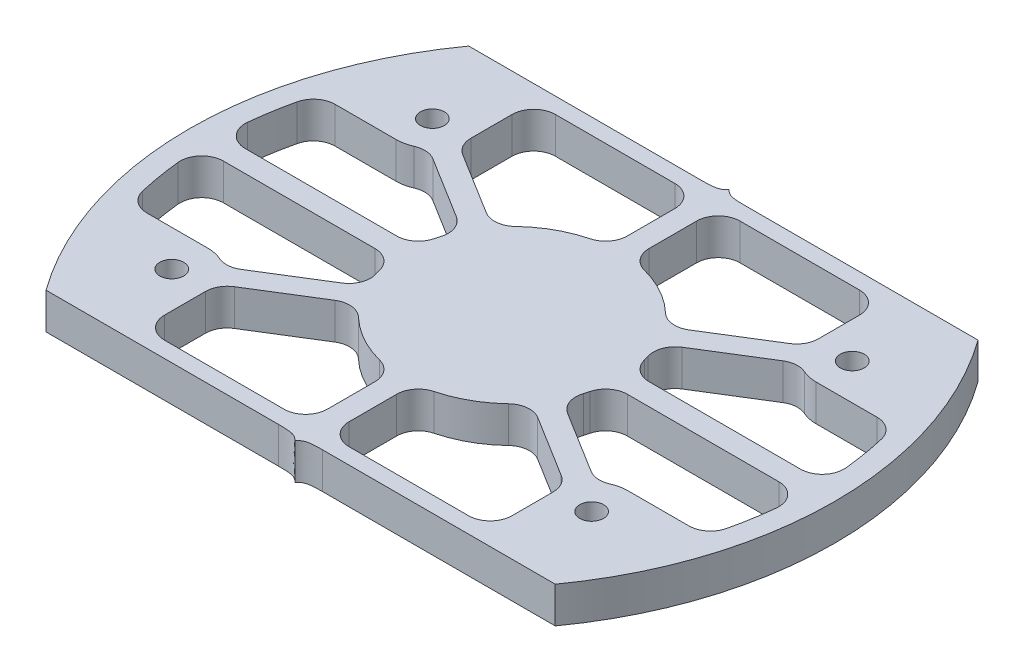
from build123d import *

# Parameters (mm, degrees)
EXTRUDE_1_DEPTH     = 5
CUT_EXTRUDE_1_DEPTH = 6
SKETCH_3_R          = 5
EXTRUDE_2_DEPTH     = 5
EXTRUDE_2_2_DEPTH   = 5
EXTRUDE_2_3_DEPTH   = 5
EXTRUDE_2_4_DEPTH   = 5
SKETCH_3_R_2        = 15
EXTRUDE_2_5_DEPTH   = 5
EXTRUDE_3_DEPTH     = 5
EXTRUDE_4_DEPTH     = 5
FILLET_1_R          = 3
M4X0_71_D           = 3.3
CUT_EXTRUDE_2_DEPTH = 6.0000001


with BuildPart() as part:
    # Эскиз1 → Бобышка-Вытянуть1 (new body)
    with BuildSketch(Plane(origin=(0, 0, 0), x_dir=(1, 0, 0), z_dir=(0, 1, 0))):
        with BuildLine():
            Line((79.165543512, 0), (10, 0))
            ThreePointArc((10, 0), (0, 30), (10, 60))
            Line((10, 60), (79.165543512, 60))
            ThreePointArc((79.165543512, 60), (89.165543512, 30), (79.165543512, 0))
        make_face()
    extrude(amount=EXTRUDE_1_DEPTH)

    # Эскиз2 → Вырез-Вытянуть1 (cut, through all)
    with BuildSketch(Plane(origin=(0, 5, 0), x_dir=(1, 0, 0), z_dir=(0, 1, 0))):
        with BuildLine():
            Line((11.529231877, 3), (77.636311635, 3))
            ThreePointArc((77.636311635, 3), (86.165543512, 30), (77.636311635, 57))
            Line((77.636311635, 57), (11.529231877, 57))
            ThreePointArc((11.529231877, 57), (3, 30), (11.529231877, 3))
        make_face()
    extrude(amount=-CUT_EXTRUDE_1_DEPTH, mode=Mode.SUBTRACT)



with BuildPart() as body_2:
    # Эскиз3 → Бобышка-Вытянуть2 (new body, through all)
    with BuildSketch(Plane(origin=(0, 5, 0), x_dir=(1, 0, 0), z_dir=(0, 1, 0))):
        with Locations((15.582771756, 48)):
            Circle(SKETCH_3_R)
    extrude(amount=-EXTRUDE_2_DEPTH)


with BuildPart() as body_3:
    # Эскиз3 → Extrude 2 2 (new body, through all)
    with BuildSketch(Plane(origin=(0, 5, 0), x_dir=(1, 0, 0), z_dir=(0, 1, 0))):
        with Locations((73.582771756, 48)):
            Circle(SKETCH_3_R)
    extrude(amount=-EXTRUDE_2_2_DEPTH)


with BuildPart() as body_4:
    # Эскиз3 → Extrude 2 3 (new body, through all)
    with BuildSketch(Plane(origin=(0, 5, 0), x_dir=(1, 0, 0), z_dir=(0, 1, 0))):
        with Locations((73.582771756, 12)):
            Circle(SKETCH_3_R)
    extrude(amount=-EXTRUDE_2_3_DEPTH)


with BuildPart() as body_5:
    # Эскиз3 → Extrude 2 4 (new body, through all)
    with BuildSketch(Plane(origin=(0, 5, 0), x_dir=(1, 0, 0), z_dir=(0, 1, 0))):
        with Locations((15.582771756, 12)):
            Circle(SKETCH_3_R)
    extrude(amount=-EXTRUDE_2_4_DEPTH)


with BuildPart() as body_6:
    # Эскиз3 → Extrude 2 5 (new body, through all)
    with BuildSketch(Plane(origin=(0, 5, 0), x_dir=(1, 0, 0), z_dir=(0, 1, 0))):
        with Locations((44.582771756, 30)):
            Circle(SKETCH_3_R_2)
    extrude(amount=-EXTRUDE_2_5_DEPTH)


with BuildPart() as part_1:
    add(part.part)

    add(body_2.part)  # Бобышка-Вытянуть3 merges body 2

    add(body_3.part)  # Бобышка-Вытянуть3 merges body 3

    add(body_4.part)  # Бобышка-Вытянуть3 merges body 4

    add(body_5.part)  # Бобышка-Вытянуть3 merges body 5

    add(body_6.part)  # Бобышка-Вытянуть3 merges body 6
    # Эскиз4 → Бобышка-Вытянуть3 (add, through all)
    with BuildSketch(Plane(origin=(0, 5, 0), x_dir=(1, 0, 0), z_dir=(0, 1, 0))):
        with BuildLine():
            ThreePointArc((31.111008092, 36.596331085), (31.838169263, 37.910442927), (32.693096677, 39.145251583))
            Line((32.693096677, 39.145251583), (20.426341357, 46.759099713))
            ThreePointArc((20.426341357, 46.759099713), (19.830972587, 45.363185691), (18.844252772, 44.210179215))
            Line((18.844252772, 44.210179215), (31.111008092, 36.596331085))
        make_face()
        with BuildLine():
            ThreePointArc((43.082771756, 44.924811557), (44.582771756, 45), (46.082771756, 44.924811557))
            Line((46.082771756, 44.924811557), (46.082771756, 57))
            Line((46.082771756, 57), (43.082771756, 57))
            Line((43.082771756, 57), (43.082771756, 44.924811557))
        make_face()
        with BuildLine():
            Line((68.739202155, 46.759099713), (56.472446835, 39.145251583))
            ThreePointArc((56.472446835, 39.145251583), (57.327374249, 37.910442927), (58.05453542, 36.596331085))
            Line((58.05453542, 36.596331085), (70.32129074, 44.210179215))
            ThreePointArc((70.32129074, 44.210179215), (69.334570925, 45.363185691), (68.739202155, 46.759099713))
        make_face()
        with BuildLine():
            Line((86.141601244, 31.5), (59.507583313, 31.5))
            ThreePointArc((59.507583313, 31.5), (59.563962853, 30.750941626), (59.582771756, 30))
            ThreePointArc((59.582771756, 30), (59.563962853, 29.249058374), (59.507583313, 28.5))
            Line((59.507583313, 28.5), (86.141601244, 28.5))
            Line((86.141601244, 28.5), (86.672716069, 28.5))
            Line((86.672716069, 28.5), (86.672716069, 31.5))
            Line((86.672716069, 31.5), (86.141601244, 31.5))
        make_face()
        with BuildLine():
            Line((70.32129074, 15.789820785), (58.05453542, 23.403668915))
            ThreePointArc((58.05453542, 23.403668915), (57.327374249, 22.089557073), (56.472446835, 20.854748417))
            Line((56.472446835, 20.854748417), (68.739202155, 13.240900287))
            ThreePointArc((68.739202155, 13.240900287), (69.334570925, 14.636814309), (70.32129074, 15.789820785))
        make_face()
        with BuildLine():
            Line((46.082771756, 3), (46.082771756, 15.075188443))
            ThreePointArc((46.082771756, 15.075188443), (44.582771756, 15), (43.082771756, 15.075188443))
            Line((43.082771756, 15.075188443), (43.082771756, 3))
            Line((43.082771756, 3), (46.082771756, 3))
        make_face()
        with BuildLine():
            ThreePointArc((32.693096677, 20.854748417), (31.838169263, 22.089557073), (31.111008092, 23.403668915))
            Line((31.111008092, 23.403668915), (18.844252772, 15.789820785))
            ThreePointArc((18.844252772, 15.789820785), (19.830972587, 14.636814309), (20.426341357, 13.240900287))
            Line((20.426341357, 13.240900287), (32.693096677, 20.854748417))
        make_face()
        with BuildLine():
            ThreePointArc((29.657960199, 28.5), (29.582771756, 30), (29.657960199, 31.5))
            Line((29.657960199, 31.5), (3.023942268, 31.5))
            Line((3.023942268, 31.5), (2.402125711, 31.5))
            Line((2.402125711, 31.5), (2.402125711, 28.5))
            Line((2.402125711, 28.5), (3.023942268, 28.5))
            Line((3.023942268, 28.5), (29.657960199, 28.5))
        make_face()
    extrude(amount=-EXTRUDE_3_DEPTH)

    # Эскиз5 → Бобышка-Вытянуть4 (add, through all)
    with BuildSketch(Plane.XZ):
        with BuildLine():
            Line((20.582771756, -3), (20.582771756, -12))
            ThreePointArc((20.582771756, -12), (12.04723785, -8.464466094), (15.582771756, -17))
            Line((15.582771756, -17), (4.833640837, -17))
            ThreePointArc((4.833640837, -17), (7.599619516, -9.721742312), (11.529231877, -3))
            Line((11.529231877, -3), (20.582771756, -3))
        make_face()
        with BuildLine():
            Line((84.331902675, -17), (73.582771756, -17))
            ThreePointArc((73.582771756, -17), (77.118305662, -8.464466094), (68.582771756, -12))
            Line((68.582771756, -12), (68.582771756, -3))
            Line((68.582771756, -3), (77.636311635, -3))
            ThreePointArc((77.636311635, -3), (81.565923996, -9.721742312), (84.331902675, -17))
        make_face()
        with BuildLine():
            Line((77.636311635, -57), (68.582771756, -57))
            Line((68.582771756, -57), (68.582771756, -48))
            ThreePointArc((68.582771756, -48), (77.118305662, -51.535533906), (73.582771756, -43))
            Line((73.582771756, -43), (84.331902675, -43))
            ThreePointArc((84.331902675, -43), (81.565923996, -50.278257688), (77.636311635, -57))
        make_face()
        with BuildLine():
            Line((11.529231877, -57), (20.582771756, -57))
            Line((20.582771756, -57), (20.582771756, -48))
            ThreePointArc((20.582771756, -48), (12.04723785, -51.535533906), (15.582771756, -43))
            Line((15.582771756, -43), (4.833640837, -43))
            ThreePointArc((4.833640837, -43), (7.599619516, -50.278257688), (11.529231877, -57))
        make_face()
    extrude(amount=-EXTRUDE_4_DEPTH)

    # Скругление1
    fillet_1_edges = [part_1.edges().sort_by_distance(p)[0] for p in [
        (70.32129074, 2.5, -44.210179215),
        (58.05453542, 2.5, -36.596331085),
        (59.507583313, 2.5, -31.5),
        (59.507583313, 2.5, -28.5),
        (58.05453542, 2.5, -23.403668915),
        (70.32129074, 2.5, -15.789820785),
        (84.331902675, 2.5, -17),
        (86.141601244, 2.5, -28.5),
        (86.141601244, 2.5, -31.5),
        (84.331902675, 2.5, -43),
        (56.472446835, 2.5, -39.145251583),
        (46.082771756, 2.5, -44.924811557),
        (46.082771756, 2.5, -57),
        (68.582771756, 2.5, -57),
        (68.739202155, 2.5, -46.759099713),
        (43.082771756, 2.5, -44.924811557),
        (43.082771756, 2.5, -57),
        (20.582771756, 2.5, -57),
        (32.693096677, 2.5, -39.145251583),
        (20.426341357, 2.5, -46.759099713),
        (31.111008092, 2.5, -36.596331085),
        (18.844252772, 2.5, -44.210179215),
        (4.833640837, 2.5, -43),
        (3.023942268, 2.5, -31.5),
        (29.657960199, 2.5, -31.5),
        (29.657960199, 2.5, -28.5),
        (3.023942268, 2.5, -28.5),
        (4.833640837, 2.5, -17),
        (18.844252772, 2.5, -15.789820785),
        (31.111008092, 2.5, -23.403668915),
        (43.082771756, 2.5, -3),
        (20.582771756, 2.5, -3),
        (20.426341357, 2.5, -13.240900287),
        (32.693096677, 2.5, -20.854748417),
        (43.082771756, 2.5, -15.075188443),
        (56.472446835, 2.5, -20.854748417),
        (46.082771756, 2.5, -15.075188443),
        (46.082771756, 2.5, -3),
        (68.582771756, 2.5, -3),
        (68.739202155, 2.5, -13.240900287),
    ]]
    fillet(fillet_1_edges, radius=FILLET_1_R)

    # Отверстие обработанное метчиком M4x0.71 (through all)
    with Locations(Plane(origin=(0, 0, 0), x_dir=(-1, 0, 0), z_dir=(0, -1, 0))):
        with Locations((-15.582771756, 12), (-73.582771756, 12), (-73.582771756, 48), (-15.582771756, 48)):
            Hole(M4X0_71_D / 2)

    # Эскиз8 → Вырез-Вытянуть2 (cut, through all)
    with BuildSketch(Plane.XZ):
        with BuildLine():
            ThreePointArc((10, 0), (9.704173203, -0.398541543), (9.412317139, -0.8))
            Line((9.412317139, -0.8), (41.52777131, -0.8))
            add(Edge.make_bspline(
                [(44.582771756, 0), (43.959141321, -0.703584088), (43.274165183, -0.8), (41.52777131, -0.8)],
                knots=[0, 0, 0, 0, 1, 1, 1, 1], degree=3))
            Line((44.582771756, 0), (10, 0))
        make_face()
        with BuildLine():
            Line((79.165543512, 0), (44.582771756, 0))
            add(Edge.make_bspline(
                [(44.582771756, 0), (45.206402191, -0.703584088), (45.891378329, -0.8), (47.637772202, -0.8)],
                knots=[0, 0, 0, 0, 1, 1, 1, 1], degree=3))
            Line((47.637772202, -0.8), (79.753226373, -0.8))
            ThreePointArc((79.753226373, -0.8), (79.461370308, -0.398541543), (79.165543512, 0))
        make_face()
        with BuildLine():
            Line((10, -60), (44.582771756, -60))
            add(Edge.make_bspline(
                [(44.582771756, -60), (43.959141321, -59.296415912), (43.274165183, -59.2), (41.52777131, -59.2)],
                knots=[0, 0, 0, 0, 1, 1, 1, 1], degree=3))
            Line((41.52777131, -59.2), (9.412317139, -59.2))
            ThreePointArc((9.412317139, -59.2), (9.704173203, -59.601458457), (10, -60))
        make_face()
        with BuildLine():
            Line((44.582771756, -60), (79.165543512, -60))
            ThreePointArc((79.165543512, -60), (79.461370308, -59.601458457), (79.753226373, -59.2))
            Line((79.753226373, -59.2), (47.637772202, -59.2))
            add(Edge.make_bspline(
                [(44.582771756, -60), (45.206402191, -59.296415912), (45.891378329, -59.2), (47.637772202, -59.2)],
                knots=[0, 0, 0, 0, 1, 1, 1, 1], degree=3))
        make_face()
    extrude(amount=-CUT_EXTRUDE_2_DEPTH, mode=Mode.SUBTRACT)


solid = part_1.part
